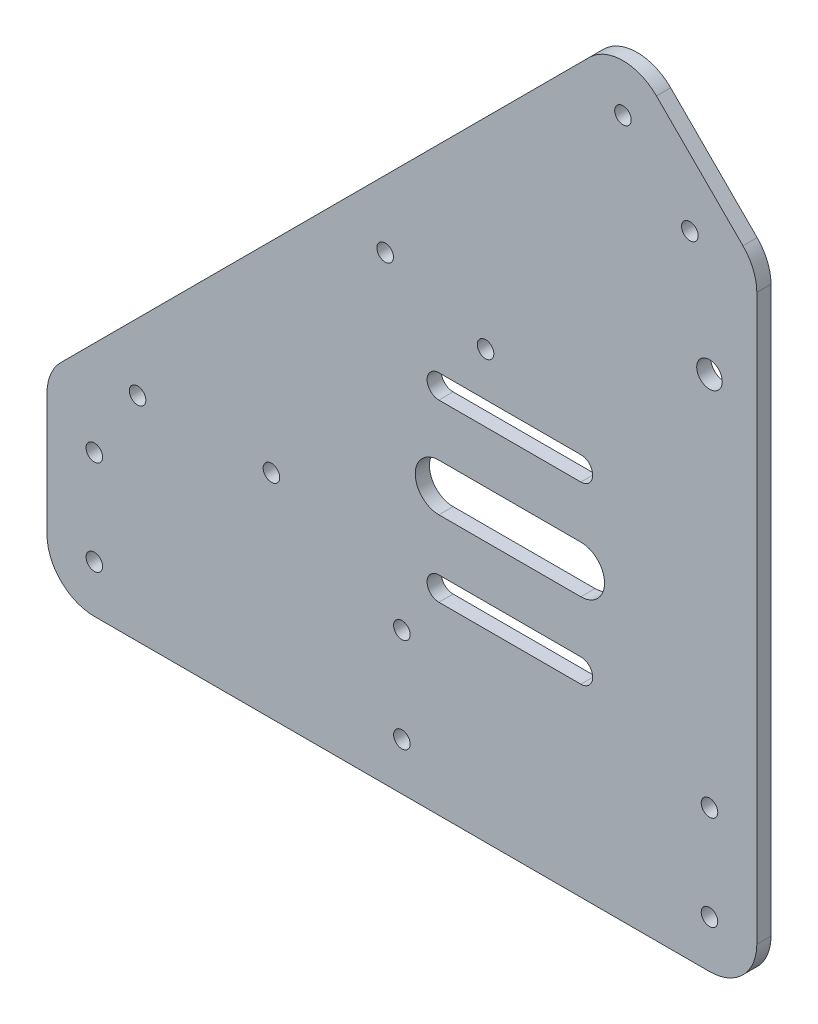
from build123d import *

# Parameters (mm, degrees)
SKETCH1_R           = 1.75
SKETCH1_R_2         = 2.7
BOSS_EXTRUDE1_DEPTH = 3
FILLET1_R           = 10


with BuildPart() as part:
    # Sketch1 → Boss-Extrude1 (new body)
    with BuildSketch(Plane.XY):
        Polygon((46.715728753, 141.715728753), (-75, 20), (-75, -20), (75, -20), (75, 20), (75, 113.431457505), align=None)
        with Locations((-65, -10)):
            Circle(SKETCH1_R, mode=Mode.SUBTRACT)
        with Locations((-65, 10)):
            Circle(SKETCH1_R, mode=Mode.SUBTRACT)
        with Locations((0, 10)):
            Circle(SKETCH1_R, mode=Mode.SUBTRACT)
        with Locations((-55.857864376, 25)):
            Circle(SKETCH1_R, mode=Mode.SUBTRACT)
        with Locations((-27.573593129, 25)):
            Circle(SKETCH1_R, mode=Mode.SUBTRACT)
        with Locations((0, -10)):
            Circle(SKETCH1_R, mode=Mode.SUBTRACT)
        with Locations((65, -10)):
            Circle(SKETCH1_R, mode=Mode.SUBTRACT)
        with Locations((65, 10)):
            Circle(SKETCH1_R, mode=Mode.SUBTRACT)
        with BuildLine():
            ThreePointArc((7.820236345, 19), (5.320236345, 21.5), (7.820236345, 24))
            Line((7.820236345, 24), (37.820236345, 24))
            ThreePointArc((37.820236345, 24), (40.320236345, 21.5), (37.820236345, 19))
            Line((37.820236345, 19), (7.820236345, 19))
        make_face(mode=Mode.SUBTRACT)
        with BuildLine():
            ThreePointArc((7.820236345, 35), (2.820236345, 40), (7.820236345, 45))
            Line((7.820236345, 45), (37.820236345, 45))
            ThreePointArc((37.820236345, 45), (42.820236345, 40), (37.820236345, 35))
            Line((37.820236345, 35), (7.820236345, 35))
        make_face(mode=Mode.SUBTRACT)
        with BuildLine():
            ThreePointArc((7.820236345, 56), (5.320236345, 58.5), (7.820236345, 61))
            Line((7.820236345, 61), (37.820236345, 61))
            ThreePointArc((37.820236345, 61), (40.320236345, 58.5), (37.820236345, 56))
            Line((37.820236345, 56), (7.820236345, 56))
        make_face(mode=Mode.SUBTRACT)
        with Locations((-3.535533906, 77.32233047)):
            Circle(SKETCH1_R, mode=Mode.SUBTRACT)
        with Locations((17.67766953, 70.251262658)):
            Circle(SKETCH1_R, mode=Mode.SUBTRACT)
        with Locations((65, 89.289321881)):
            Circle(SKETCH1_R_2, mode=Mode.SUBTRACT)
        with Locations((60.857864376, 113.431457505)):
            Circle(SKETCH1_R, mode=Mode.SUBTRACT)
        with Locations((46.715728753, 127.573593129)):
            Circle(SKETCH1_R, mode=Mode.SUBTRACT)
    extrude(amount=BOSS_EXTRUDE1_DEPTH)

    # Fillet1
    fillet1_edges = [part.edges().sort_by_distance(p)[0] for p in [
        (75, -20, 1.5),
        (-75, -20, 1.5),
        (-75, 20, 1.5),
        (46.715728753, 141.715728753, 1.5),
        (75, 113.431457505, 1.5),
    ]]
    fillet(fillet1_edges, radius=FILLET1_R)


solid = part.part
